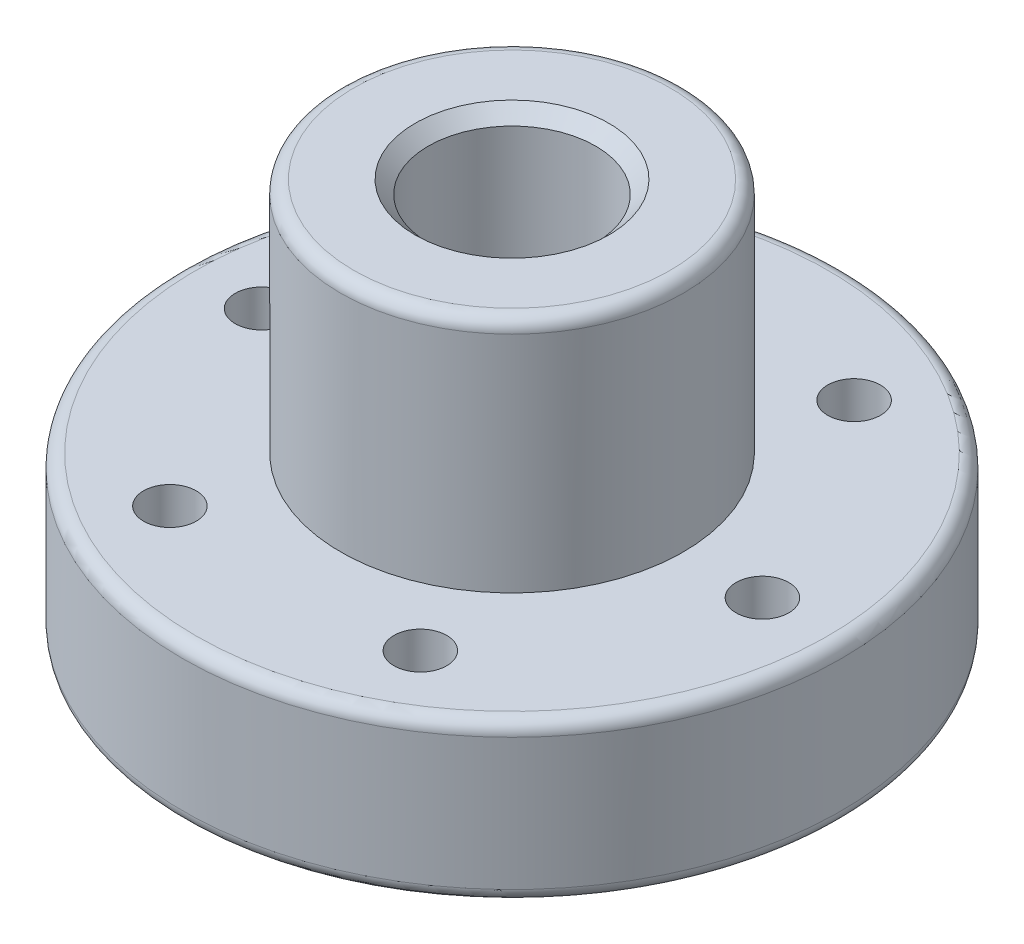
from build123d import *

# Parameters (mm, degrees)
ESQUISSE3_R                  = 1
ENL_V_MAT_EXTRU_1_DEPTH      = 7
R_P_TITION_CIRCULAIRE1_COUNT = 6
CONG_1_R                     = 0.5
CHANFREIN1_SIZE              = 0.5


with BuildPart() as part:
    # Esquisse1 → Révolution2 (revolve)
    with BuildSketch(Plane.XY):
        Polygon((6.5, 15), (6.5, 6), (12.5, 6), (12.5, 0), (3.175, 0), (3.175, 15), align=None)
    revolve(axis=Axis((0, 0, 0), (0, 1, 0)))

    # Esquisse3 → Enlèv. mat.-Extru.1 (cut, through all)
    with BuildSketch(Plane(origin=(0, 6, 0), x_dir=(1, 0, 0), z_dir=(0, 1, 0))):
        with Locations((9.5, 0)):
            Circle(ESQUISSE3_R)
    enl_v_mat_extru_1 = extrude(amount=-ENL_V_MAT_EXTRU_1_DEPTH, mode=Mode.SUBTRACT)

    # Répétition circulaire1: Enlèv. mat.-Extru.1 ×6 about axis
    r_p_tition_circulaire1_axis = Axis((0, 0, 0), (0, 1, 0))
    for i in range(1, R_P_TITION_CIRCULAIRE1_COUNT):
        add(enl_v_mat_extru_1.rotate(r_p_tition_circulaire1_axis, i * 360 / R_P_TITION_CIRCULAIRE1_COUNT), mode=Mode.SUBTRACT)

    # Congé1
    cong_1_edges = [part.edges().sort_by_distance(p)[0] for p in [
        (-6.5, 15, 0),
        (-12.5, 6, 0),
        (-12.5, 0, 0),
    ]]
    fillet(cong_1_edges, radius=CONG_1_R)

    # Chanfrein1
    chanfrein1_edges = [part.edges().sort_by_distance(p)[0] for p in [
        (-3.175, 0, 0),
        (-3.175, 15, 0),
    ]]
    chamfer(chanfrein1_edges, length=CHANFREIN1_SIZE)


solid = part.part
